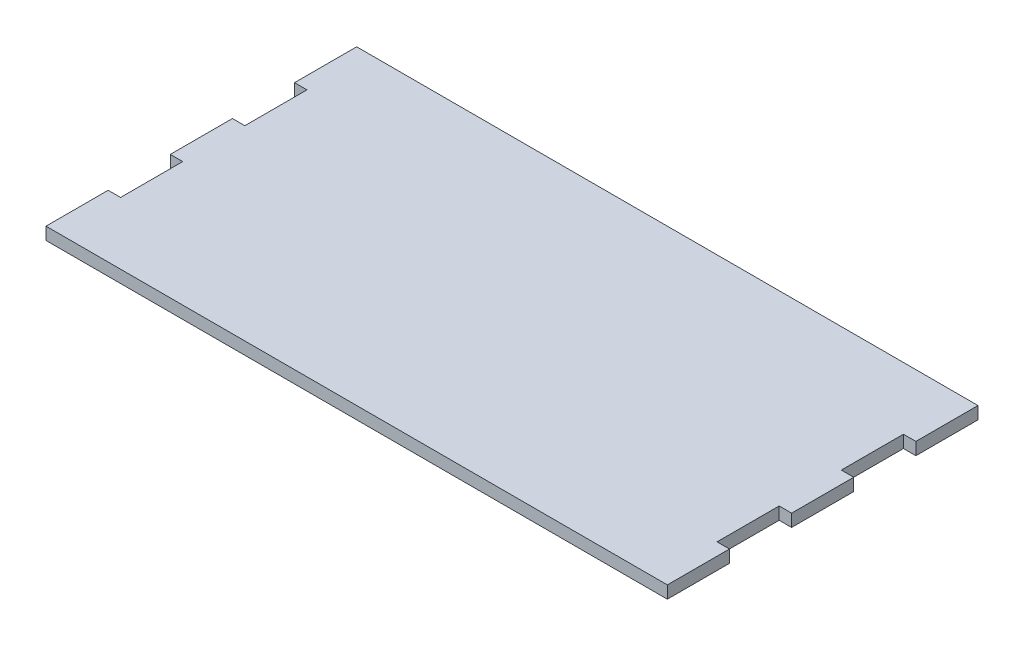
from build123d import *

# Parameters (mm, degrees)
SKETCH3_W           = 250
SKETCH3_H           = 125
BOSS_EXTRUDE1_DEPTH = 5
SKETCH10_W          = 5
SKETCH10_H          = 25
CUT_EXTRUDE4_DEPTH  = 6
SKETCH11_W          = 240
SKETCH11_H          = 5
CUT_EXTRUDE5_DEPTH  = 2.5


with BuildPart() as part:
    # Sketch3 → Boss-Extrude1 (new body)
    with BuildSketch(Plane(origin=(0, 0, 0), x_dir=(1, 0, 0), z_dir=(0, 1, 0))):
        with Locations((125, 62.5)):
            Rectangle(SKETCH3_W, SKETCH3_H)
    extrude(amount=BOSS_EXTRUDE1_DEPTH)

    # Sketch10 → Cut-Extrude4 (cut, through all)
    with BuildSketch(Plane(origin=(0, 5, 0), x_dir=(1, 0, 0), z_dir=(0, 1, 0))):
        with Locations((2.5, 87.5)):
            Rectangle(SKETCH10_W, SKETCH10_H)
        with Locations((247.5, 37.5)):
            Rectangle(SKETCH10_W, SKETCH10_H)
        with Locations((2.5, 37.5)):
            Rectangle(SKETCH10_W, SKETCH10_H)
        with Locations((247.5, 87.5)):
            Rectangle(SKETCH10_W, SKETCH10_H)
    extrude(amount=-CUT_EXTRUDE4_DEPTH, mode=Mode.SUBTRACT)

    # Sketch11 → Cut-Extrude5 (cut)
    with BuildSketch(Plane.XZ):
        with Locations((125, -12.5)):
            Rectangle(SKETCH11_W, SKETCH11_H)
    extrude(amount=-CUT_EXTRUDE5_DEPTH, mode=Mode.SUBTRACT)


solid = part.part
